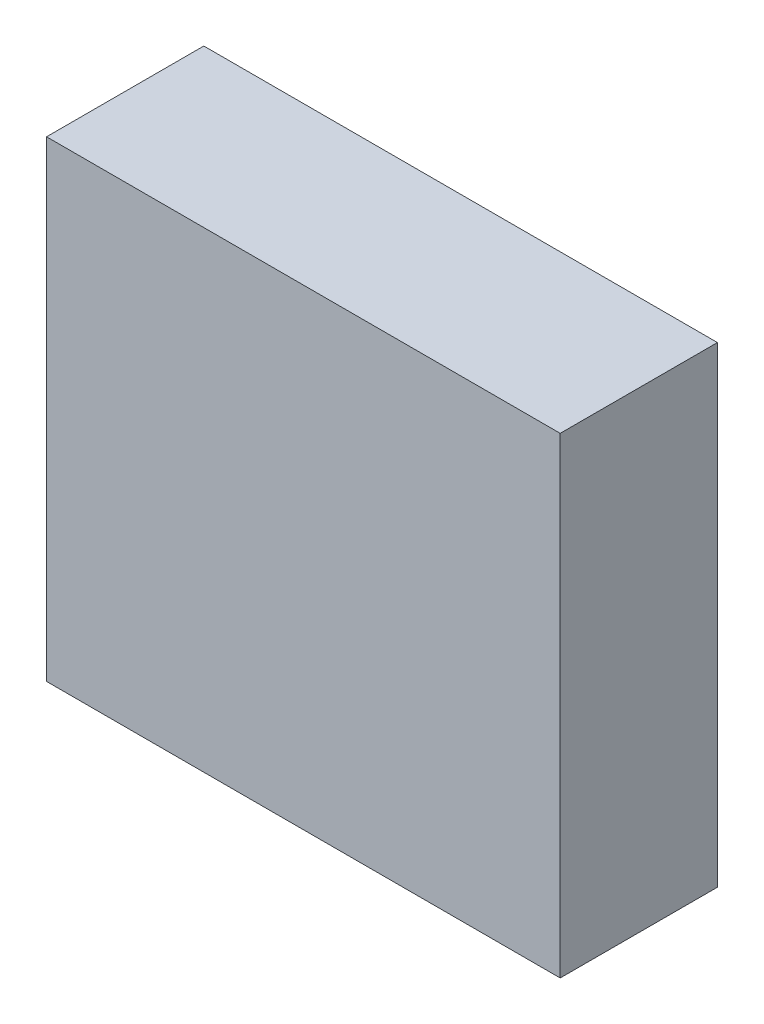
from build123d import *

# Parameters (mm, degrees)
ESQUISSE2_W        = 98
ESQUISSE2_H        = 30
BOSS_EXTRU_1_DEPTH = 90


with BuildPart() as part:
    # Esquisse2 → Boss.-Extru.1 (new body)
    with BuildSketch(Plane(origin=(0, 0, 0), x_dir=(1, 0, 0), z_dir=(0, 1, 0))):
        Rectangle(ESQUISSE2_W, ESQUISSE2_H)
    extrude(amount=BOSS_EXTRU_1_DEPTH)


solid = part.part
